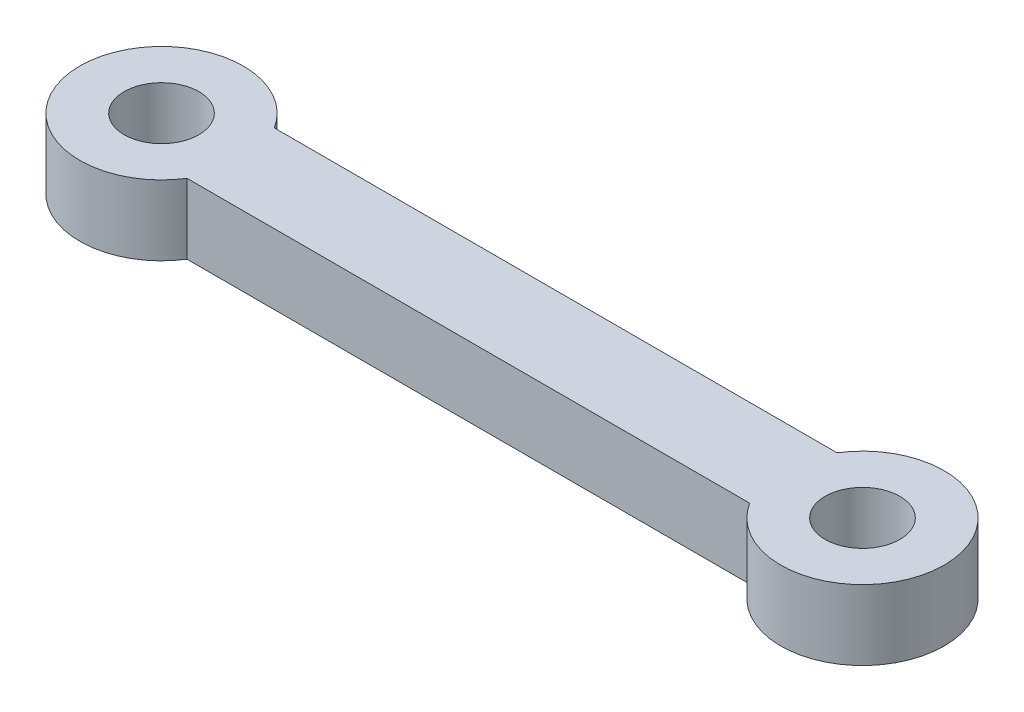
from build123d import *

# Parameters (mm, degrees)
SKETCH1_R           = 1.6
BOSS_EXTRUDE1_DEPTH = 3


with BuildPart() as part:
    # Sketch1 → Boss-Extrude1 (new body)
    with BuildSketch(Plane(origin=(0, 0, 0), x_dir=(1, 0, 0), z_dir=(0, 1, 0))):
        with BuildLine():
            Line((27.040220901, 1.868075932), (2.959779099, 1.868075932))
            ThreePointArc((2.959779099, 1.868075932), (-3.5, 0), (2.959779099, -1.868075932))
            Line((2.959779099, -1.868075932), (27.040220901, -1.868075932))
            ThreePointArc((27.040220901, -1.868075932), (33.5, 0), (27.040220901, 1.868075932))
        make_face()
        Circle(SKETCH1_R, mode=Mode.SUBTRACT)
        with Locations((30, 0)):
            Circle(SKETCH1_R, mode=Mode.SUBTRACT)
    extrude(amount=BOSS_EXTRUDE1_DEPTH)


solid = part.part
